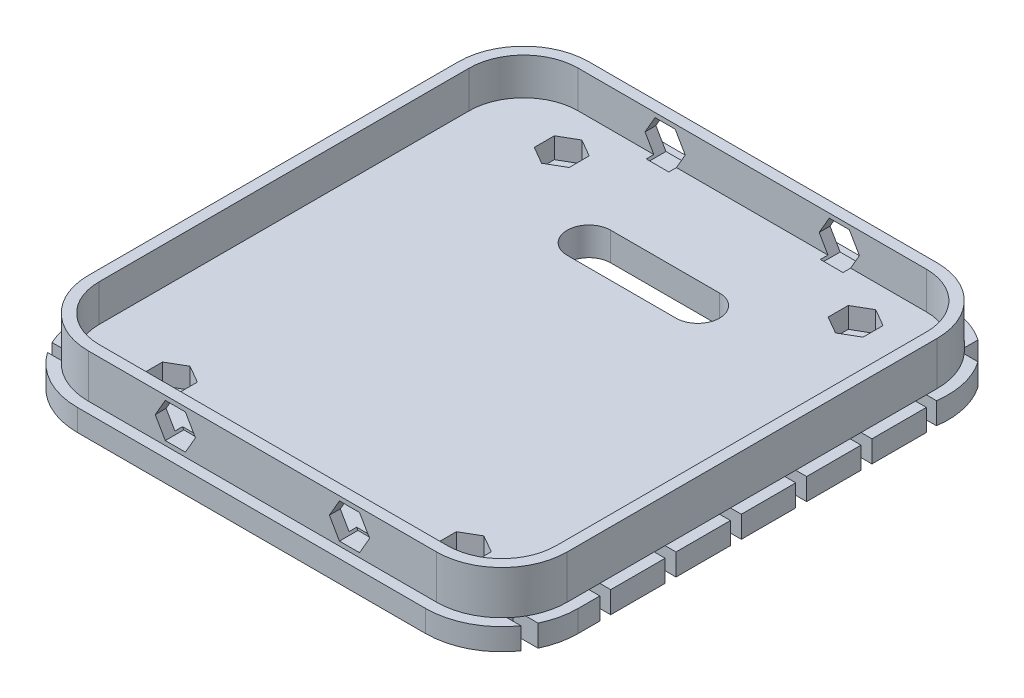
from build123d import *

# Parameters (mm, degrees)
SKETCH1_W           = 220
SKETCH1_H           = 230
BOSS_EXTRUDE1_DEPTH = 20
FILLET1_R           = 30
BOSS_EXTRUDE4_DEPTH = 10
CUT_EXTRUDE10_DEPTH = 17
SKETCH7_R           = 5
CUT_EXTRUDE3_DEPTH  = 31
SKETCH8_R           = 5
CUT_EXTRUDE4_DEPTH  = 30
SKETCH13_R          = 5
CUT_EXTRUDE5_DEPTH  = 30
CUT_EXTRUDE6_DEPTH  = 8.5
CUT_EXTRUDE7_DEPTH  = 8.5
CUT_EXTRUDE8_DEPTH  = 26.5
CUT_EXTRUDE9_DEPTH  = 31


with BuildPart() as part:
    # Sketch1 → Boss-Extrude1 (new body)
    with BuildSketch(Plane(origin=(0, 0, 0), x_dir=(1, 0, 0), z_dir=(0, 1, 0))):
        with Locations((110, 115)):
            Rectangle(SKETCH1_W, SKETCH1_H)
    extrude(amount=BOSS_EXTRUDE1_DEPTH)

    # Fillet1
    fillet1_edges = [part.edges().sort_by_distance(p)[0] for p in [
        (0, 10, -230),
        (220, 10, -230),
        (220, 10, 0),
        (0, 10, 0),
    ]]
    fillet(fillet1_edges, radius=FILLET1_R)

    # Sketch4 → Boss-Extrude4 (add)
    with BuildSketch(Plane(origin=(0, 0, 0), x_dir=(-1, 0, 0), z_dir=(0, -1, 0))):
        with BuildLine():
            Line((-210, 10), (-218.722813233, 10))
            ThreePointArc((-218.722813233, 10), (-206.201851746, -1.024184115), (-190, -5))
            Line((-190, -5), (-30, -5))
            ThreePointArc((-30, -5), (-13.798148254, -1.024184115), (-1.277186767, 10))
            Line((-1.277186767, 10), (-10, 10))
            Line((-10, 10), (-10, 15))
            Line((-10, 15), (1.622776602, 15))
            ThreePointArc((1.622776602, 15), (4.145257219, 22.312255892), (5, 30))
            Line((5, 30), (5, 40))
            Line((5, 40), (-10, 40))
            Line((-10, 40), (-10, 45))
            Line((-10, 45), (5, 45))
            Line((5, 45), (5, 70))
            Line((5, 70), (-10, 70))
            Line((-10, 70), (-10, 75))
            Line((-10, 75), (5, 75))
            Line((5, 75), (5, 100))
            Line((5, 100), (-10, 100))
            Line((-10, 100), (-10, 105))
            Line((-10, 105), (5, 105))
            Line((5, 105), (5, 130))
            Line((5, 130), (-10, 130))
            Line((-10, 130), (-10, 135))
            Line((-10, 135), (5, 135))
            Line((5, 135), (5, 160))
            Line((5, 160), (-10, 160))
            Line((-10, 160), (-10, 165))
            Line((-10, 165), (5, 165))
            Line((5, 165), (5, 190))
            Line((5, 190), (-10, 190))
            Line((-10, 190), (-10, 195))
            Line((-10, 195), (4.641016151, 195))
            ThreePointArc((4.641016151, 195), (4.058680517, 208.062647298), (-1.277186767, 220))
            Line((-1.277186767, 220), (-10, 220))
            Line((-10, 220), (-10, 228.722813233))
            ThreePointArc((-10, 228.722813233), (-19.519028269, 233.393850206), (-30, 235))
            Line((-30, 235), (-190, 235))
            ThreePointArc((-190, 235), (-200.480971731, 233.393850206), (-210, 228.722813233))
            Line((-210, 228.722813233), (-210, 220))
            Line((-210, 220), (-218.722813233, 220))
            ThreePointArc((-218.722813233, 220), (-224.058680517, 208.062647298), (-224.641016151, 195))
            Line((-224.641016151, 195), (-210, 195))
            Line((-210, 195), (-210, 190))
            Line((-210, 190), (-225, 190))
            Line((-225, 190), (-225, 165))
            Line((-225, 165), (-210, 165))
            Line((-210, 165), (-210, 160))
            Line((-210, 160), (-225, 160))
            Line((-225, 160), (-225, 135))
            Line((-225, 135), (-210, 135))
            Line((-210, 135), (-210, 130))
            Line((-210, 130), (-225, 130))
            Line((-225, 130), (-225, 105))
            Line((-225, 105), (-210, 105))
            Line((-210, 105), (-210, 100))
            Line((-210, 100), (-225, 100))
            Line((-225, 100), (-225, 75))
            Line((-225, 75), (-210, 75))
            Line((-210, 75), (-210, 70))
            Line((-210, 70), (-225, 70))
            Line((-225, 70), (-225, 45))
            Line((-225, 45), (-210, 45))
            Line((-210, 45), (-210, 40))
            Line((-210, 40), (-225, 40))
            Line((-225, 40), (-225, 30))
            ThreePointArc((-225, 30), (-224.145257219, 22.312255892), (-221.622776602, 15))
            Line((-221.622776602, 15), (-210, 15))
            Line((-210, 15), (-210, 10))
        make_face()
    extrude(amount=BOSS_EXTRUDE4_DEPTH)

    # Sketch20 → Cut-Extrude10 (cut)
    with BuildSketch(Plane(origin=(0, 20, 0), x_dir=(1, 0, 0), z_dir=(0, 1, 0))):
        with BuildLine():
            Line((215, 30), (215, 200))
            ThreePointArc((215, 200), (207.67766953, 217.67766953), (190, 225))
            Line((190, 225), (30, 225))
            ThreePointArc((30, 225), (12.32233047, 217.67766953), (5, 200))
            Line((5, 200), (5, 30))
            ThreePointArc((5, 30), (12.32233047, 12.32233047), (30, 5))
            Line((30, 5), (190, 5))
            ThreePointArc((190, 5), (207.67766953, 12.32233047), (215, 30))
        make_face()
    extrude(amount=-CUT_EXTRUDE10_DEPTH, mode=Mode.SUBTRACT)

    # Sketch7 → Cut-Extrude3 (cut, through all)
    with BuildSketch(Plane(origin=(0, -10, 0), x_dir=(-1, 0, 0), z_dir=(0, -1, 0))):
        with Locations((-42.5, 25)):
            Circle(SKETCH7_R)
        with Locations((-177.5, 25)):
            Circle(SKETCH7_R)
        with Locations((-177.5, 205)):
            Circle(SKETCH7_R)
        with Locations((-42.5, 205)):
            Circle(SKETCH7_R)
    extrude(amount=-CUT_EXTRUDE3_DEPTH, mode=Mode.SUBTRACT)

    # Sketch8 → Cut-Extrude4 (cut)
    with BuildSketch(Plane(origin=(0, 0, -230), x_dir=(-1, 0, 0), z_dir=(0, 0, -1))):
        with Locations((-150, 10)):
            Circle(SKETCH8_R)
        with Locations((-70, 10)):
            Circle(SKETCH8_R)
    extrude(amount=-CUT_EXTRUDE4_DEPTH, mode=Mode.SUBTRACT)

    # Sketch13 → Cut-Extrude5 (cut)
    with BuildSketch(Plane.XY):
        with Locations((70, 10)):
            Circle(SKETCH13_R)
        with Locations((150, 10)):
            Circle(SKETCH13_R)
    extrude(amount=-CUT_EXTRUDE5_DEPTH, mode=Mode.SUBTRACT)

    # Sketch17 → Cut-Extrude6 (cut)
    with BuildSketch(Plane.XY):
        Polygon((60.762395693, 10), (65.381197846, 2), (74.618802154, 2), (79.237604307, 10), (74.618802154, 18), (65.381197846, 18), align=None)
        Polygon((154.618802154, 18), (159.237604307, 10), (154.618802154, 2), (145.381197846, 2), (140.762395693, 10), (145.381197846, 18), align=None)
    extrude(amount=-CUT_EXTRUDE6_DEPTH, mode=Mode.SUBTRACT)

    # Sketch16 → Cut-Extrude7 (cut)
    with BuildSketch(Plane(origin=(0, 0, -230), x_dir=(-1, 0, 0), z_dir=(0, 0, -1))):
        Polygon((-159.237604307, 10), (-154.618802154, 2), (-145.381197846, 2), (-140.762395693, 10), (-145.381197846, 18), (-154.618802154, 18), align=None)
        Polygon((-65.381197846, 18), (-60.762395693, 10), (-65.381197846, 2), (-74.618802154, 2), (-79.237604307, 10), (-74.618802154, 18), align=None)
    extrude(amount=-CUT_EXTRUDE7_DEPTH, mode=Mode.SUBTRACT)

    # Sketch18 → Cut-Extrude8 (cut)
    with BuildSketch(Plane(origin=(0, 20, 0), x_dir=(1, 0, 0), z_dir=(0, 1, 0))):
        Polygon((42.5, 195.762395693), (50.5, 200.381197846), (50.5, 209.618802154), (42.5, 214.237604307), (34.5, 209.618802154), (34.5, 200.381197846), align=None)
        Polygon((185.5, 200.381197846), (177.5, 195.762395693), (169.5, 200.381197846), (169.5, 209.618802154), (177.5, 214.237604307), (185.5, 209.618802154), align=None)
        Polygon((185.5, 20.381197846), (185.5, 29.618802154), (177.5, 34.237604307), (169.5, 29.618802154), (169.5, 20.381197846), (177.5, 15.762395693), align=None)
        Polygon((34.5, 29.618802154), (42.5, 34.237604307), (50.5, 29.618802154), (50.5, 20.381197846), (42.5, 15.762395693), (34.5, 20.381197846), align=None)
    extrude(amount=-CUT_EXTRUDE8_DEPTH, mode=Mode.SUBTRACT)

    # Sketch19 → Cut-Extrude9 (cut, through all)
    with BuildSketch(Plane(origin=(0, 20, 0), x_dir=(1, 0, 0), z_dir=(0, 1, 0))):
        with BuildLine():
            Line((85, 185), (135, 185))
            ThreePointArc((135, 185), (145, 175), (135, 165))
            Line((135, 165), (85, 165))
            ThreePointArc((85, 165), (75, 175), (85, 185))
        make_face()
    extrude(amount=-CUT_EXTRUDE9_DEPTH, mode=Mode.SUBTRACT)


solid = part.part
